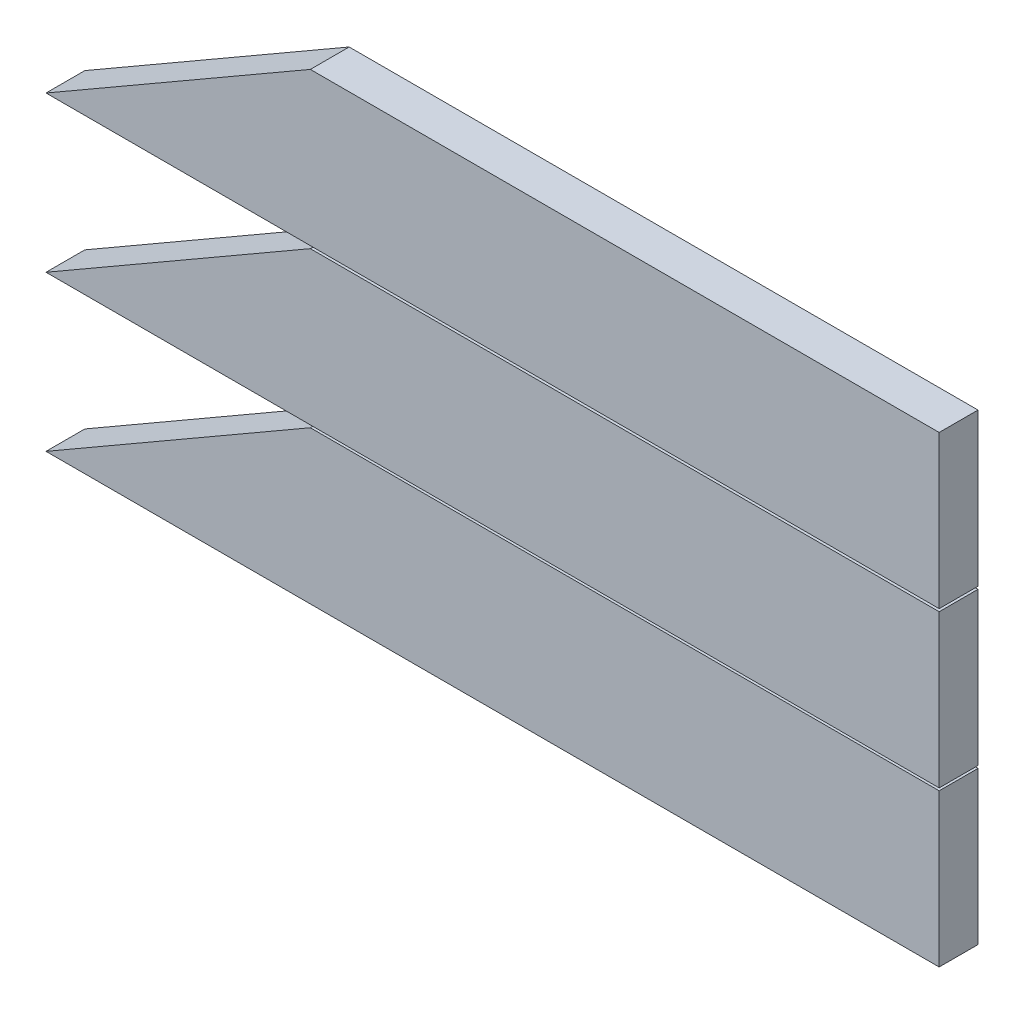
from build123d import *

# Parameters (mm, degrees)
BOSS_EXTRUDE1_DEPTH   = 25.4
BOSS_EXTRUDE1_2_DEPTH = 25.4
BOSS_EXTRUDE1_3_DEPTH = 25.4


with BuildPart() as part:
    # Sketch1 → Boss-Extrude1 (new body)
    with BuildSketch(Plane.XY):
        Polygon((0, 0), (-411.303224287, 0), (-584.2, -99.822), (0, -99.822), align=None)
    extrude(amount=BOSS_EXTRUDE1_DEPTH)


with BuildPart() as body_2:
    # Sketch1 → Boss-Extrude1 2 (new body)
    with BuildSketch(Plane.XY):
        Polygon((0, 101.539691072), (-411.303224287, 101.539691072), (-584.2, 1.717691072), (0, 1.717691072), align=None)
    extrude(amount=BOSS_EXTRUDE1_2_DEPTH)


with BuildPart() as body_3:
    # Sketch1 → Boss-Extrude1 3 (new body)
    with BuildSketch(Plane.XY):
        Polygon((0, -101.445836193), (-411.303224287, -101.445836193), (-584.2, -201.267836193), (0, -201.267836193), align=None)
    extrude(amount=BOSS_EXTRUDE1_3_DEPTH)


solid = Compound([part.part, body_2.part, body_3.part])
